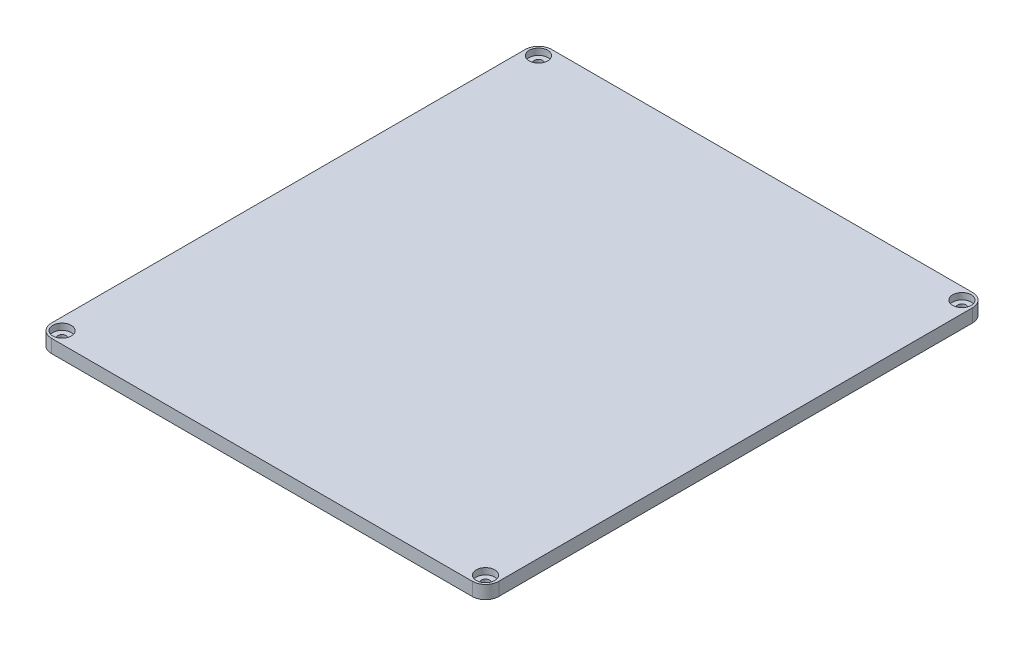
from build123d import *

# Parameters (mm, degrees)
SALIENTE_EXTRUIR2_DEPTH                     = 5
REFRENTADO_PARA_TORNILLO_CON_CABEZA_2_COUNT = 2
REFRENTADO_PARA_TORNILLO_CON_CABEZA_2_PITCH = 180
REFRENTADO_PARA_TORNILLO_CON_CABEZA_3_COUNT = 2
REFRENTADO_PARA_TORNILLO_CON_CABEZA_3_PITCH = 240.831891576
REFRENTADO_PARA_TORNILLO_CON_CABEZA_4_COUNT = 2
REFRENTADO_PARA_TORNILLO_CON_CABEZA_4_PITCH = 160
CORTAR_EXTRUIR1_DEPTH                       = 2
CROQUIS8_W                                  = 10
CROQUIS8_H                                  = 10
SALIENTE_EXTRUIR7_DEPTH                     = 5
TALADRO_DE_MARGEN_PARA_M31_D                = 3.2
TALADRO_DE_MARGEN_PARA_M31_DEPTH            = 5
TALADRO_DE_MARGEN_PARA_M31_TIP              = 0.96137699


with BuildPart() as part:
    # Croquis1 → Saliente-Extruir2 (new body)
    with BuildSketch(Plane(origin=(0, 0, 0), x_dir=(1, 0, 0), z_dir=(0, 1, 0))):
        with BuildLine():
            Line((-79.5, -94.5), (79.5, -94.5))
            ThreePointArc((79.5, -94.5), (83.035533906, -93.035533906), (84.5, -89.5))
            Line((84.5, -89.5), (84.5, 89.5))
            ThreePointArc((84.5, 89.5), (83.035533906, 93.035533906), (79.5, 94.5))
            Line((79.5, 94.5), (-79.5, 94.5))
            ThreePointArc((-79.5, 94.5), (-83.035533906, 93.035533906), (-84.5, 89.5))
            Line((-84.5, 89.5), (-84.5, -89.5))
            ThreePointArc((-84.5, -89.5), (-83.035533906, -93.035533906), (-79.5, -94.5))
        make_face()
    extrude(amount=SALIENTE_EXTRUIR2_DEPTH)

    # Croquis5 → Refrentado para tornillo con cabeza troncocónica de M31 (revolve, cut)
    with BuildSketch(Plane(origin=(80, 5, -90), x_dir=(0, 0, 1), z_dir=(1, 0, 0))):
        Polygon((0, 0), (0, 5), (1.6, 5), (1.6, 2.4), (3.5, 2.4), (3.5, -2), (1.5, 0), align=None)
    refrentado_para_tornillo_con_cabeza_tron = revolve(axis=Axis((80, 11.35, -90), (0, -1, 0)), mode=Mode.SUBTRACT)

    # Refrentado para tornillo con cabeza  2: Refrentado para tornillo con cabeza troncocónica de M31 ×2
    with Locations(*[(0, 0, i * REFRENTADO_PARA_TORNILLO_CON_CABEZA_2_PITCH) for i in range(1, REFRENTADO_PARA_TORNILLO_CON_CABEZA_2_COUNT)]):
        add(refrentado_para_tornillo_con_cabeza_tron, mode=Mode.SUBTRACT)

    # Refrentado para tornillo con cabeza  3: Refrentado para tornillo con cabeza troncocónica de M31 ×2
    with Locations(*[Vector(-0.664363839, 0, 0.747409319) * (i * REFRENTADO_PARA_TORNILLO_CON_CABEZA_3_PITCH) for i in range(1, REFRENTADO_PARA_TORNILLO_CON_CABEZA_3_COUNT)]):
        add(refrentado_para_tornillo_con_cabeza_tron, mode=Mode.SUBTRACT)

    # Refrentado para tornillo con cabeza  4: Refrentado para tornillo con cabeza troncocónica de M31 ×2
    with Locations(*[(-i * REFRENTADO_PARA_TORNILLO_CON_CABEZA_4_PITCH, 0, 0) for i in range(1, REFRENTADO_PARA_TORNILLO_CON_CABEZA_4_COUNT)]):
        add(refrentado_para_tornillo_con_cabeza_tron, mode=Mode.SUBTRACT)

    # Croquis6 → Cortar-Extruir1 (cut)
    with BuildSketch(Plane.XZ):
        Polygon((-81, 84), (-74, 91), (74, 91), (81, 84), (81, -84), (74, -91), (-74, -91), (-81, -84), align=None)
    extrude(amount=-CORTAR_EXTRUIR1_DEPTH, mode=Mode.SUBTRACT)

    # Croquis8 → Saliente-Extruir7 (add)
    with BuildSketch(Plane.XZ.offset(-2)):
        with Locations((-76, 79)):
            Rectangle(CROQUIS8_W, CROQUIS8_H)
        with Locations((76, 79)):
            Rectangle(CROQUIS8_W, CROQUIS8_H)
        with Locations((-76, -79)):
            Rectangle(CROQUIS8_W, CROQUIS8_H)
        with Locations((76, -79)):
            Rectangle(CROQUIS8_W, CROQUIS8_H)
    extrude(amount=SALIENTE_EXTRUIR7_DEPTH)

    # Taladro de margen para M31
    with Locations(Plane(origin=(0, -3, 0), x_dir=(-1, 0, 0), z_dir=(0, -1, 0))):
        with Locations((-76, 79), (76, 79), (76, -79), (-76, -79)):
            Hole(TALADRO_DE_MARGEN_PARA_M31_D / 2, depth=TALADRO_DE_MARGEN_PARA_M31_DEPTH)
            with Locations((0, 0, -(TALADRO_DE_MARGEN_PARA_M31_DEPTH + TALADRO_DE_MARGEN_PARA_M31_TIP / 2))):  # 118° drill point
                Cone(0, TALADRO_DE_MARGEN_PARA_M31_D / 2, TALADRO_DE_MARGEN_PARA_M31_TIP, mode=Mode.SUBTRACT)


solid = part.part
